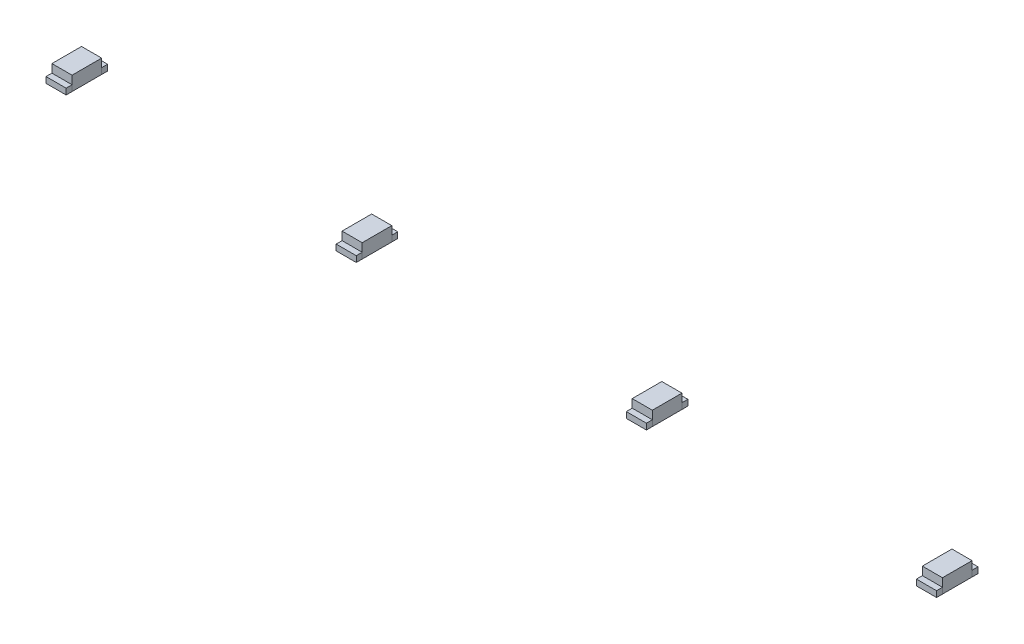
from build123d import *

# Parameters (mm, degrees)
SKETCH1_W             = 0.85
SKETCH1_H             = 1.25
BOSS_EXTRUDE1_DEPTH   = 0.6
BOSS_EXTRUDE1_2_DEPTH = 0.6
BOSS_EXTRUDE1_3_DEPTH = 0.6
BOSS_EXTRUDE1_4_DEPTH = 0.6
SKETCH2_W             = 0.85
SKETCH2_H             = 0.25
BOSS_EXTRUDE2_DEPTH   = 0.25


with BuildPart() as part:
    # Sketch1 → Boss-Extrude1 (new body)
    with BuildSketch(Plane(origin=(0, 0, 0), x_dir=(1, 0, 0), z_dir=(0, 1, 0))):
        with Locations((-18.375, 0)):
            Rectangle(SKETCH1_W, SKETCH1_H)
    extrude(amount=BOSS_EXTRUDE1_DEPTH)



with BuildPart() as body_2:
    # Sketch1 → Boss-Extrude1 2 (new body)
    with BuildSketch(Plane(origin=(0, 0, 0), x_dir=(1, 0, 0), z_dir=(0, 1, 0))):
        with Locations((18.375, 0)):
            Rectangle(SKETCH1_W, SKETCH1_H)
    extrude(amount=BOSS_EXTRUDE1_2_DEPTH)


with BuildPart() as body_3:
    # Sketch1 → Boss-Extrude1 3 (new body)
    with BuildSketch(Plane(origin=(0, 0, 0), x_dir=(1, 0, 0), z_dir=(0, 1, 0))):
        with Locations((-6.125, 0)):
            Rectangle(SKETCH1_W, SKETCH1_H)
    extrude(amount=BOSS_EXTRUDE1_3_DEPTH)


with BuildPart() as body_4:
    # Sketch1 → Boss-Extrude1 4 (new body)
    with BuildSketch(Plane(origin=(0, 0, 0), x_dir=(1, 0, 0), z_dir=(0, 1, 0))):
        with Locations((6.125, 0)):
            Rectangle(SKETCH1_W, SKETCH1_H)
    extrude(amount=BOSS_EXTRUDE1_4_DEPTH)


with BuildPart() as part_1:
    add(part.part)

    add(body_2.part)  # Boss-Extrude2 merges body 2

    add(body_3.part)  # Boss-Extrude2 merges body 3

    add(body_4.part)  # Boss-Extrude2 merges body 4
    # Sketch2 → Boss-Extrude2 (add)
    with BuildSketch(Plane(origin=(0, 0, 0), x_dir=(1, 0, 0), z_dir=(0, 1, 0))):
        with Locations((-18.375, 0.75)):
            Rectangle(SKETCH2_W, SKETCH2_H)
        with Locations((-6.125, 0.75)):
            Rectangle(SKETCH2_W, SKETCH2_H)
        with Locations((6.125, 0.75)):
            Rectangle(SKETCH2_W, SKETCH2_H)
        with Locations((18.375, 0.75)):
            Rectangle(SKETCH2_W, SKETCH2_H)
        with Locations((18.375, -0.75)):
            Rectangle(SKETCH2_W, SKETCH2_H)
        with Locations((6.125, -0.75)):
            Rectangle(SKETCH2_W, SKETCH2_H)
        with Locations((-6.125, -0.75)):
            Rectangle(SKETCH2_W, SKETCH2_H)
        with Locations((-18.375, -0.75)):
            Rectangle(SKETCH2_W, SKETCH2_H)
    extrude(amount=BOSS_EXTRUDE2_DEPTH)


solid = part_1.part
